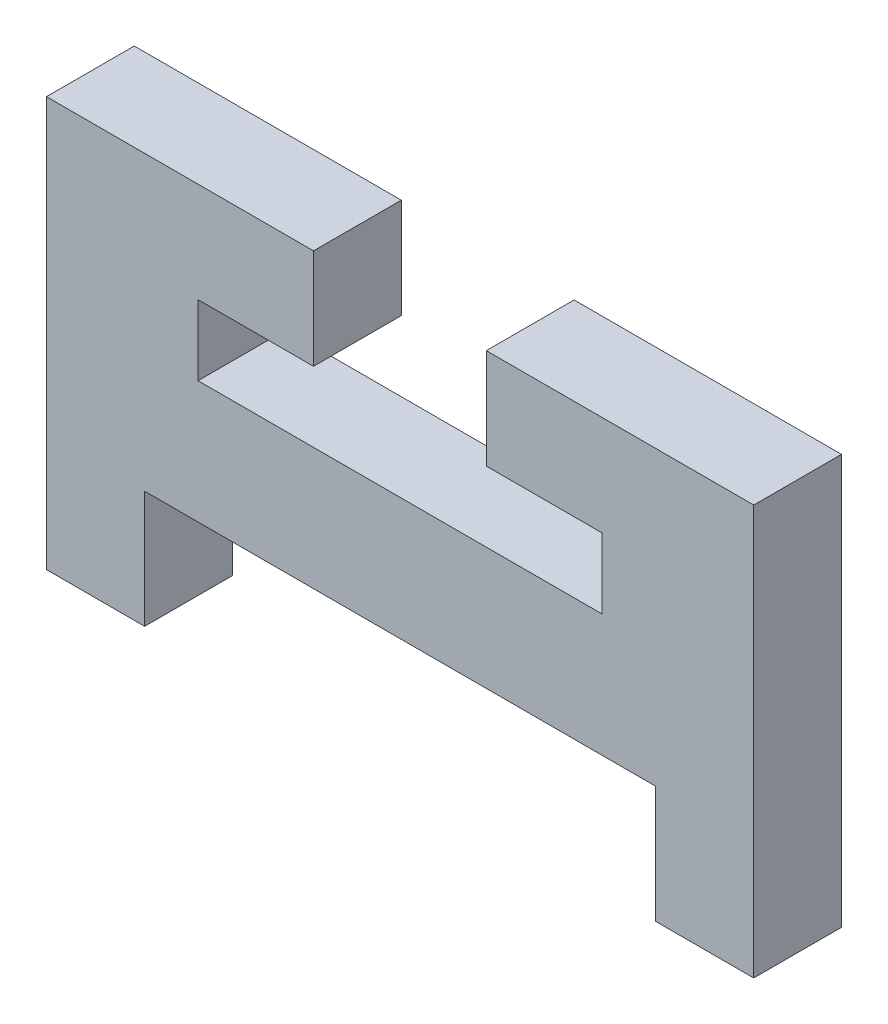
from build123d import *

# Parameters (mm, degrees)
SALIENTE_EXTRUIR1_DEPTH = 3


with BuildPart() as part:
    # Model → Saliente-Extruir1 (new body)
    with BuildSketch(Plane.XY):
        Polygon((31.7, 16.782683294), (24.293333333, 16.782683294), (24.293333333, 19.182683294), (28.24, 19.182683294), (28.24, 22.6), (19.113333333, 22.6), (19.113333333, 8.6), (22.468, 8.6), (22.468, 12.6), (39.932, 12.6), (39.932, 8.6), (43.286666667, 8.6), (43.286666667, 22.6), (34.14656693, 22.6), (34.14656693, 19.182683294), (38.106666667, 19.182683294), (38.106666667, 16.782683294), align=None)
    extrude(amount=SALIENTE_EXTRUIR1_DEPTH)


solid = part.part
